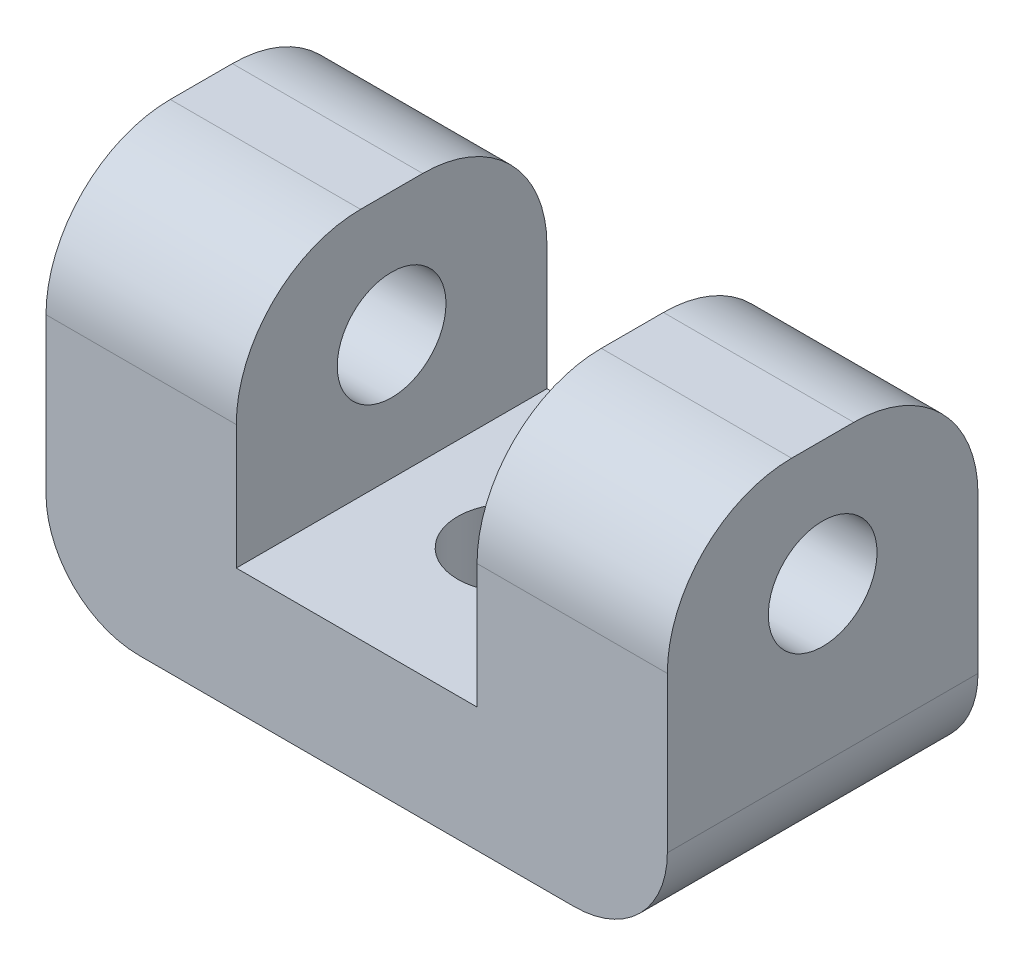
from build123d import *

# Parameters (mm, degrees)
SKETCH1_W           = 20
SKETCH1_H           = 10
BOSS_EXTRUDE1_DEPTH = 12
SKETCH2_W           = 7.749887486
SKETCH2_H           = 10
CUT_EXTRUDE1_DEPTH  = 8
FILLET1_R           = 4
SKETCH3_R           = 1.75
CUT_EXTRUDE2_DEPTH  = 21
FILLET2_R           = 3
SKETCH4_R           = 1.75
CUT_EXTRUDE3_DEPTH  = 5


with BuildPart() as part:
    # Sketch1 → Boss-Extrude1 (new body)
    with BuildSketch(Plane(origin=(0, 0, 0), x_dir=(1, 0, 0), z_dir=(0, 1, 0))):
        Rectangle(SKETCH1_W, SKETCH1_H)
    extrude(amount=BOSS_EXTRUDE1_DEPTH)

    # Sketch2 → Cut-Extrude1 (cut)
    with BuildSketch(Plane(origin=(0, 12, 0), x_dir=(1, 0, 0), z_dir=(0, 1, 0))):
        Rectangle(SKETCH2_W, SKETCH2_H)
    extrude(amount=-CUT_EXTRUDE1_DEPTH, mode=Mode.SUBTRACT)

    # Fillet1
    fillet1_edges = [part.edges().sort_by_distance(p)[0] for p in [
        (-6.937471871, 12, -5),
        (6.937471871, 12, 5),
        (-6.937471871, 12, 5),
        (6.937471871, 12, -5),
    ]]
    fillet(fillet1_edges, radius=FILLET1_R)

    # Sketch3 → Cut-Extrude2 (cut, through all)
    with BuildSketch(Plane(origin=(10, 0, 0), x_dir=(0, 0, -1), z_dir=(1, 0, 0))):
        with Locations((0, 8)):
            Circle(SKETCH3_R)
    extrude(amount=-CUT_EXTRUDE2_DEPTH, mode=Mode.SUBTRACT)

    # Fillet2
    fillet2_edges = [part.edges().sort_by_distance(p)[0] for p in [
        (-10, 0, 0),
        (10, 0, 0),
    ]]
    fillet(fillet2_edges, radius=FILLET2_R)

    # Sketch4 → Cut-Extrude3 (cut, through all)
    with BuildSketch(Plane(origin=(0, 4, 0), x_dir=(1, 0, 0), z_dir=(0, 1, 0))):
        Circle(SKETCH4_R)
    extrude(amount=-CUT_EXTRUDE3_DEPTH, mode=Mode.SUBTRACT)


solid = part.part
